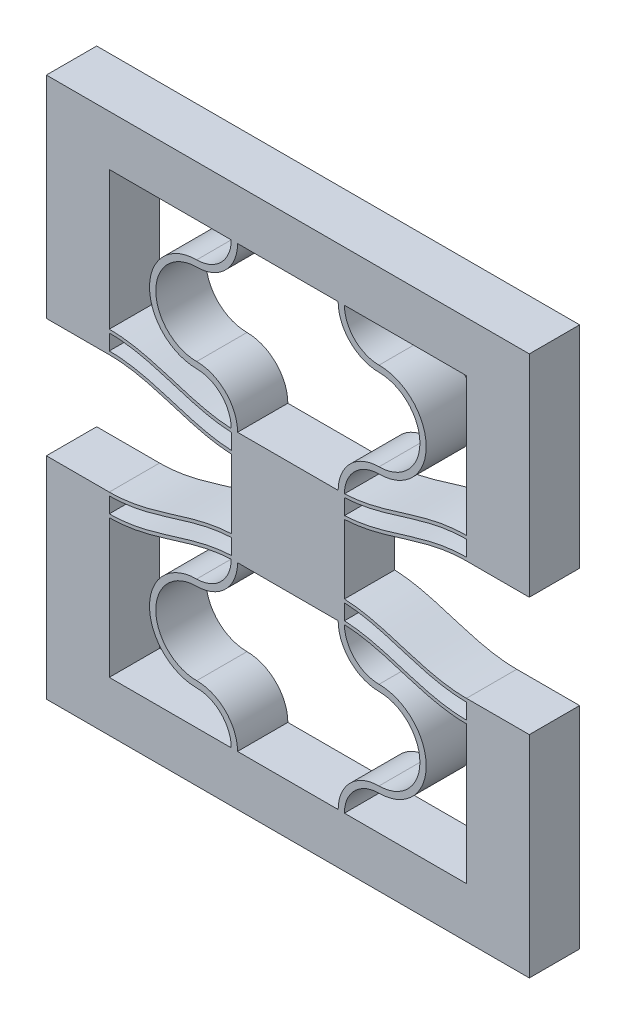
from build123d import *

# Parameters (mm, degrees)
BOSS_EXTRUDE1_DEPTH = 4
SKETCH4_W           = 1.000050945
SKETCH4_H           = 4
BOSS_EXTRUDE2_DEPTH = 1.5
SKETCH7_W           = 4
SKETCH7_H           = 4
SKETCH7_H_2         = 8.976327255
BOSS_EXTRUDE3_DEPTH = 4


with BuildPart() as part:
    # Sketch1 → Boss-Extrude1 (new body)
    with BuildSketch(Plane.XY):
        with BuildLine():
            add(Edge.make_bspline(
                [(10.700021746, 14.748163628), (10.770442209, 14.744836274), (11.036085492, 14.729945366), (11.496068343, 14.688967467), (12.277133012, 14.57654642), (13.170467922, 14.38131673), (14.052003931, 14.140619795), (14.832937753, 13.904376795), (15.393357047, 13.730980586), (15.860792907, 13.587666723), (16.235288715, 13.475094348), (16.674100849, 13.347694048), (17.099096084, 13.231500794), (17.511450041, 13.128113642), (17.925406717, 13.034967535), (18.278165441, 12.964050023), (18.646366139, 12.89968077), (19.035941161, 12.8444255), (19.420580647, 12.802032302), (19.77003147, 12.776891937), (20.046158153, 12.764231459), (20.27623218, 12.760603847), (20.359143177, 12.759999248), (20.399999999, 12.759999248)],
                knots=[0.520025221, 0.520025221, 0.520025221, 0.520025221, 0.520025221, 0.531314617, 0.562629223, 0.593943884, 0.646301981, 0.677616625, 0.70893127, 0.724588594, 0.740245918, 0.755903242, 0.771560566, 0.797739616, 0.810829141, 0.823918666, 0.839575987, 0.855233307, 0.870890611, 0.886547914, 0.902205227, 0.910033884, 0.91786254, 0.91786254, 0.91786254, 0.91786254, 0.91786254], degree=4))
            Line((10.700021746, 14.748163628), (10.700021746, 15.988163628))
            Line((10.700021746, 15.988163628), (9.699970801, 15.988163628))
            Line((9.699970801, 15.988163628), (9.699970801, 14.748163628))
            add(Edge.make_bspline(
                [(-1e-09, 12.759999248), (0.081713644, 12.759999248), (0.20022235, 12.761813041), (0.471417711, 12.767859056), (0.71802642, 12.784074907), (1.034143266, 12.807331454), (1.360460459, 12.844425484), (1.755278768, 12.89968081), (2.201212647, 12.978078229), (2.715774727, 13.085277814), (3.221006588, 13.209956277), (3.72645335, 13.347690264), (4.164438645, 13.475099721), (4.539314013, 13.587658142), (5.19353908, 13.78832691), (6.066052095, 14.059388687), (7.038292152, 14.339517772), (8.122879289, 14.576551536), (8.903926555, 14.688965271), (9.363909154, 14.729944815), (9.629551853, 14.744836231), (9.699970801, 14.748163628)],
                knots=[0.08213746, 0.08213746, 0.08213746, 0.08213746, 0.08213746, 0.097794773, 0.105623429, 0.113452086, 0.129109389, 0.144766693, 0.160424013, 0.176081334, 0.202260384, 0.228439434, 0.244096758, 0.259754082, 0.275411406, 0.29106873, 0.353698019, 0.406056116, 0.437370777, 0.468685383, 0.479974485, 0.479974485, 0.479974485, 0.479974485, 0.479974485], degree=4))
            Line((0, 12.759999248), (-5.000000005, 12.759999248))
            Line((-5.000000005, 12.759999248), (-5.000000005, -4))
            Line((-5.000000005, -4), (25.400000005, -4))
            Line((25.400000005, -4), (25.400000005, 12.759999248))
            Line((25.400000005, 12.759999248), (20.4, 12.759999248))
        make_face()
        with BuildLine():
            Line((9.699970801, 14.488163628), (9.699970801, 13.248163628))
            add(Edge.make_bspline(
                [(-1e-09, 11.259999248), (0.081713644, 11.259999248), (0.20022235, 11.261813041), (0.471417711, 11.267859056), (0.71802642, 11.284074907), (1.034143266, 11.307331454), (1.360460459, 11.344425484), (1.755278768, 11.39968081), (2.201212647, 11.478078229), (2.715774727, 11.585277814), (3.221006588, 11.709956277), (3.72645335, 11.847690264), (4.164438645, 11.975099721), (4.539314013, 12.087658142), (5.19353908, 12.28832691), (6.066052095, 12.559388687), (7.038292152, 12.839517772), (8.122879289, 13.076551536), (8.903926555, 13.188965271), (9.363909154, 13.229944815), (9.629551853, 13.244836231), (9.699970801, 13.248163628)],
                knots=[0.08213746, 0.08213746, 0.08213746, 0.08213746, 0.08213746, 0.097794773, 0.105623429, 0.113452086, 0.129109389, 0.144766693, 0.160424013, 0.176081334, 0.202260384, 0.228439434, 0.244096758, 0.259754082, 0.275411406, 0.29106873, 0.353698019, 0.406056116, 0.437370777, 0.468685383, 0.479974485, 0.479974485, 0.479974485, 0.479974485, 0.479974485], degree=4))
            Line((0, 11.259999248), (0, 12.499999248))
            add(Edge.make_bspline(
                [(-1e-09, 12.499999248), (0.081713644, 12.499999248), (0.20022235, 12.501813041), (0.471417711, 12.507859056), (0.71802642, 12.524074907), (1.034143266, 12.547331454), (1.360460459, 12.584425484), (1.755278768, 12.63968081), (2.201212647, 12.718078229), (2.715774727, 12.825277814), (3.221006588, 12.949956277), (3.72645335, 13.087690264), (4.164438645, 13.215099721), (4.539314013, 13.327658142), (5.19353908, 13.52832691), (6.066052095, 13.799388687), (7.038292152, 14.079517772), (8.122879289, 14.316551536), (8.903926555, 14.428965271), (9.363909154, 14.469944815), (9.629551853, 14.484836231), (9.699970801, 14.488163628)],
                knots=[0.08213746, 0.08213746, 0.08213746, 0.08213746, 0.08213746, 0.097794773, 0.105623429, 0.113452086, 0.129109389, 0.144766693, 0.160424013, 0.176081334, 0.202260384, 0.228439434, 0.244096758, 0.259754082, 0.275411406, 0.29106873, 0.353698019, 0.406056116, 0.437370777, 0.468685383, 0.479974485, 0.479974485, 0.479974485, 0.479974485, 0.479974485], degree=4))
        make_face(mode=Mode.SUBTRACT)
        with BuildLine():
            Line((10.700021746, 13.248163628), (10.700021746, 14.488163628))
            add(Edge.make_bspline(
                [(10.700021746, 14.488163628), (10.770442209, 14.484836274), (11.036085492, 14.469945366), (11.496068343, 14.428967467), (12.277133012, 14.31654642), (13.170467922, 14.12131673), (14.052003931, 13.880619795), (14.832937753, 13.644376795), (15.393357047, 13.470980586), (15.860792907, 13.327666723), (16.235288715, 13.215094348), (16.674100849, 13.087694048), (17.099096084, 12.971500794), (17.511450041, 12.868113642), (17.925406717, 12.774967535), (18.278165441, 12.704050023), (18.646366139, 12.63968077), (19.035941161, 12.5844255), (19.420580647, 12.542032302), (19.77003147, 12.516891937), (20.046158153, 12.504231459), (20.27623218, 12.500603847), (20.359143177, 12.499999248), (20.399999999, 12.499999248)],
                knots=[0.520025221, 0.520025221, 0.520025221, 0.520025221, 0.520025221, 0.531314617, 0.562629223, 0.593943884, 0.646301981, 0.677616625, 0.70893127, 0.724588594, 0.740245918, 0.755903242, 0.771560566, 0.797739616, 0.810829141, 0.823918666, 0.839575987, 0.855233307, 0.870890611, 0.886547914, 0.902205227, 0.910033884, 0.91786254, 0.91786254, 0.91786254, 0.91786254, 0.91786254], degree=4))
            Line((20.4, 12.499999248), (20.4, 11.259999248))
            add(Edge.make_bspline(
                [(10.700021746, 13.248163628), (10.770442209, 13.244836274), (11.036085492, 13.229945366), (11.496068342, 13.188967467), (12.277133012, 13.07654642), (13.170467922, 12.88131673), (14.052003931, 12.640619795), (14.832937753, 12.404376795), (15.393357047, 12.230980586), (15.860792907, 12.087666723), (16.235288715, 11.975094348), (16.674100849, 11.847694048), (17.099096084, 11.731500794), (17.511450041, 11.628113642), (17.925406717, 11.534967535), (18.278165441, 11.464050023), (18.646366139, 11.39968077), (19.035941161, 11.3444255), (19.420580647, 11.302032302), (19.77003147, 11.276891937), (20.046158153, 11.264231459), (20.27623218, 11.260603847), (20.359143177, 11.259999248), (20.399999999, 11.259999248)],
                knots=[0.520025221, 0.520025221, 0.520025221, 0.520025221, 0.520025221, 0.531314617, 0.562629223, 0.593943884, 0.646301981, 0.677616625, 0.70893127, 0.724588594, 0.740245918, 0.755903242, 0.771560566, 0.797739616, 0.810829141, 0.823918666, 0.839575987, 0.855233307, 0.870890611, 0.886547914, 0.902205227, 0.910033884, 0.91786254, 0.91786254, 0.91786254, 0.91786254, 0.91786254], degree=4))
        make_face(mode=Mode.SUBTRACT)
        with BuildLine():
            Line((0, 0), (0, 10.999999248))
            add(Edge.make_bspline(
                [(-1e-09, 10.999999248), (0.081713644, 10.999999248), (0.20022235, 11.001813041), (0.471417711, 11.007859056), (0.71802642, 11.024074907), (1.034143266, 11.047331454), (1.360460459, 11.084425484), (1.755278768, 11.13968081), (2.201212646, 11.218078229), (2.715774727, 11.325277814), (3.221006588, 11.449956277), (3.72645335, 11.587690264), (4.164438645, 11.715099721), (4.539314013, 11.827658142), (5.19353908, 12.02832691), (6.066052095, 12.299388687), (7.038292152, 12.579517772), (8.122879289, 12.816551536), (8.903926555, 12.928965271), (9.363909154, 12.969944815), (9.629551853, 12.984836231), (9.699970801, 12.988163628)],
                knots=[0.08213746, 0.08213746, 0.08213746, 0.08213746, 0.08213746, 0.097794773, 0.105623429, 0.113452086, 0.129109389, 0.144766693, 0.160424013, 0.176081334, 0.202260384, 0.228439434, 0.244096758, 0.259754082, 0.275411406, 0.29106873, 0.353698019, 0.406056116, 0.437370777, 0.468685383, 0.479974485, 0.479974485, 0.479974485, 0.479974485, 0.479974485], degree=4))
            ThreePointArc((9.699970801, 12.988163628), (8.890350619, 11.051276056), (6.949996273, 10.25))
            ThreePointArc((6.949996273, 10.25), (3.199996273, 6.5), (6.949996273, 2.75))
            ThreePointArc((6.949996273, 2.75), (8.894539922, 1.944543648), (9.699996273, 0))
            Line((9.699996273, 0), (0, 0))
        make_face(mode=Mode.SUBTRACT)
        with BuildLine():
            ThreePointArc((6.949996273, 9.75), (9.248093312, 10.701902961), (10.199996273, 13))
            ThreePointArc((10.199996273, 13), (11.151899235, 10.701902961), (13.449996273, 9.75))
            ThreePointArc((13.449996273, 9.75), (16.699996273, 6.5), (13.449996273, 3.25))
            ThreePointArc((13.449996273, 3.25), (11.151899235, 2.298097039), (10.199996273, 0))
            ThreePointArc((10.199996273, 0), (9.248093312, 2.298097039), (6.949996273, 3.25))
            ThreePointArc((6.949996273, 3.25), (3.699996273, 6.5), (6.949996273, 9.75))
        make_face(mode=Mode.SUBTRACT)
        with BuildLine():
            ThreePointArc((13.449996273, 10.25), (11.509641927, 11.051276056), (10.700021746, 12.988163628))
            add(Edge.make_bspline(
                [(10.700021746, 12.988163628), (10.770442209, 12.984836274), (11.036085492, 12.969945366), (11.496068342, 12.928967467), (12.277133012, 12.81654642), (13.170467922, 12.62131673), (14.052003931, 12.380619795), (14.832937753, 12.144376795), (15.393357047, 11.970980586), (15.860792907, 11.827666723), (16.235288715, 11.715094348), (16.674100849, 11.587694048), (17.099096084, 11.471500794), (17.511450041, 11.368113642), (17.925406717, 11.274967535), (18.278165441, 11.204050023), (18.646366139, 11.13968077), (19.035941161, 11.0844255), (19.420580647, 11.042032302), (19.77003147, 11.016891937), (20.046158153, 11.004231459), (20.27623218, 11.000603847), (20.359143177, 10.999999248), (20.399999999, 10.999999248)],
                knots=[0.520025221, 0.520025221, 0.520025221, 0.520025221, 0.520025221, 0.531314617, 0.562629223, 0.593943884, 0.646301981, 0.677616625, 0.70893127, 0.724588594, 0.740245918, 0.755903242, 0.771560566, 0.797739616, 0.810829141, 0.823918666, 0.839575987, 0.855233307, 0.870890611, 0.886547914, 0.902205227, 0.910033884, 0.91786254, 0.91786254, 0.91786254, 0.91786254, 0.91786254], degree=4))
            Line((20.4, 10.999999248), (20.4, 0))
            Line((20.4, 0), (10.699996273, 0))
            ThreePointArc((10.699996273, 0), (11.505452625, 1.944543648), (13.449996273, 2.75))
            ThreePointArc((13.449996273, 2.75), (17.199996273, 6.5), (13.449996273, 10.25))
        make_face(mode=Mode.SUBTRACT)
    extrude(amount=BOSS_EXTRUDE1_DEPTH)

    # Sketch4 → Boss-Extrude2 (add)
    with BuildSketch(Plane(origin=(0, 15.988163628, 0), x_dir=(1, 0, 0), z_dir=(0, 1, 0))):
        with Locations((10.199996274, -2)):
            Rectangle(SKETCH4_W, SKETCH4_H)
    extrude(amount=BOSS_EXTRUDE2_DEPTH)

    # Mirror3: part across plane


with BuildPart() as part_1:
    add(part.part)
    add(part.part.mirror(Plane.ZX.offset(17.488163628)))

    # Split2
    split(bisect_by=Plane(origin=(10.199996273, 0, 0), x_dir=(0, -1, 0), z_dir=(-1, 0, 0)), keep=Keep.BOTTOM)

    # Sketch7 → Boss-Extrude3 (add)
    with BuildSketch(Plane.ZY.offset(-10.199996273)):
        with Locations((2, 36.976327255)):
            Rectangle(SKETCH7_W, SKETCH7_H)
        with Locations((2, 17.488163628)):
            Rectangle(SKETCH7_W, SKETCH7_H_2)
        with Locations((2, -2)):
            Rectangle(SKETCH7_W, SKETCH7_H)
    extrude(amount=BOSS_EXTRUDE3_DEPTH)

    # Mirror2: part across plane


with BuildPart() as part_2:
    add(part_1.part)
    add(part_1.part.mirror(Plane.ZY.offset(-6.199996273)))


solid = part_2.part
